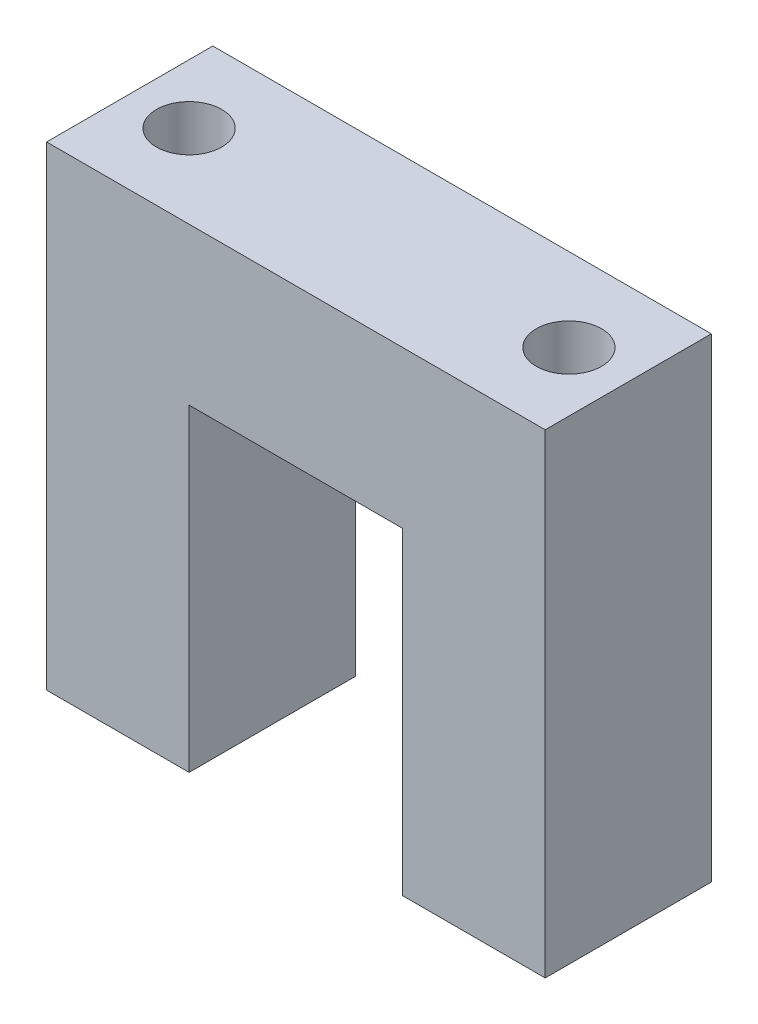
from build123d import *

# Parameters (mm, degrees)
BOSS_EXTRUDE1_DEPTH = 7
SKETCH4_R           = 2.75
CUT_EXTRUDE1_DEPTH  = 40


with BuildPart() as part:
    # Sketch3 → Boss-Extrude1 (new body, symmetric)
    with BuildSketch(Plane.XY):
        Polygon((-9, 0), (-21, 0), (-21, 40), (21, 40), (21, 0), (9, 0), (9, 26.8), (-9, 26.8), align=None)
    extrude(amount=BOSS_EXTRUDE1_DEPTH, both=True)

    # Sketch4 → Cut-Extrude1 (cut)
    with BuildSketch(Plane(origin=(0, 40, 0), x_dir=(1, 0, 0), z_dir=(0, 1, 0))):
        with Locations((-16, 0)):
            Circle(SKETCH4_R)
        with Locations((16, 0)):
            Circle(SKETCH4_R)
    extrude(amount=-CUT_EXTRUDE1_DEPTH, mode=Mode.SUBTRACT)


solid = part.part
